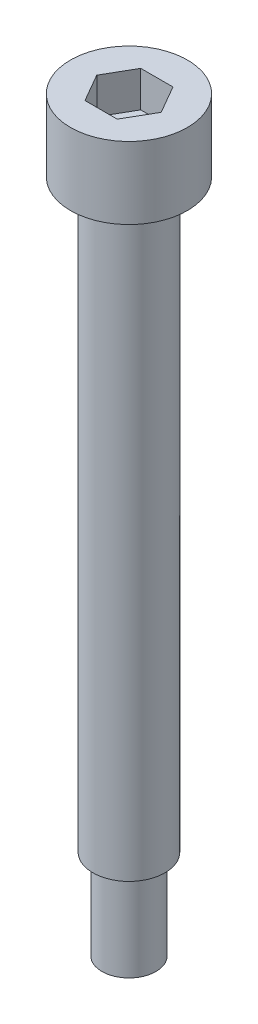
from build123d import *

# Parameters (mm, degrees)
SKETCH_1_R            = 6.5
EXTRUDE_255_DEPTH     = 8
CUT_EXTRUDE_389_DEPTH = 4
SKETCH_3_R            = 4
EXTRUDE_494_DEPTH     = 65
SKETCH_4_R            = 3
EXTRUDE_M6_DEPTH      = 10


with BuildPart() as part:
    # 草图1 → Extrude 255 (new body)
    with BuildSketch(Plane(origin=(0, 0, 0), x_dir=(1, 0, 0), z_dir=(0, 1, 0))):
        Circle(SKETCH_1_R)
    extrude(amount=EXTRUDE_255_DEPTH)

    # 草图2 → Cut-Extrude 389 (cut)
    with BuildSketch(Plane(origin=(0, 8, 0), x_dir=(1, 0, 0), z_dir=(0, 1, 0))):
        Polygon((3.579571669, 0), (1.789785834, 3.1), (-1.789785834, 3.1), (-3.579571669, 0), (-1.789785834, -3.1), (1.789785834, -3.1), align=None)
    extrude(amount=-CUT_EXTRUDE_389_DEPTH, mode=Mode.SUBTRACT)

    # 草图3 → Extrude 494 (add)
    with BuildSketch(Plane.XZ):
        Circle(SKETCH_3_R)
    extrude(amount=EXTRUDE_494_DEPTH)

    # 草图4 → M6螺纹 (add)
    with BuildSketch(Plane.XZ.offset(65)):
        Circle(SKETCH_4_R)
    extrude(amount=EXTRUDE_M6_DEPTH)


solid = part.part
